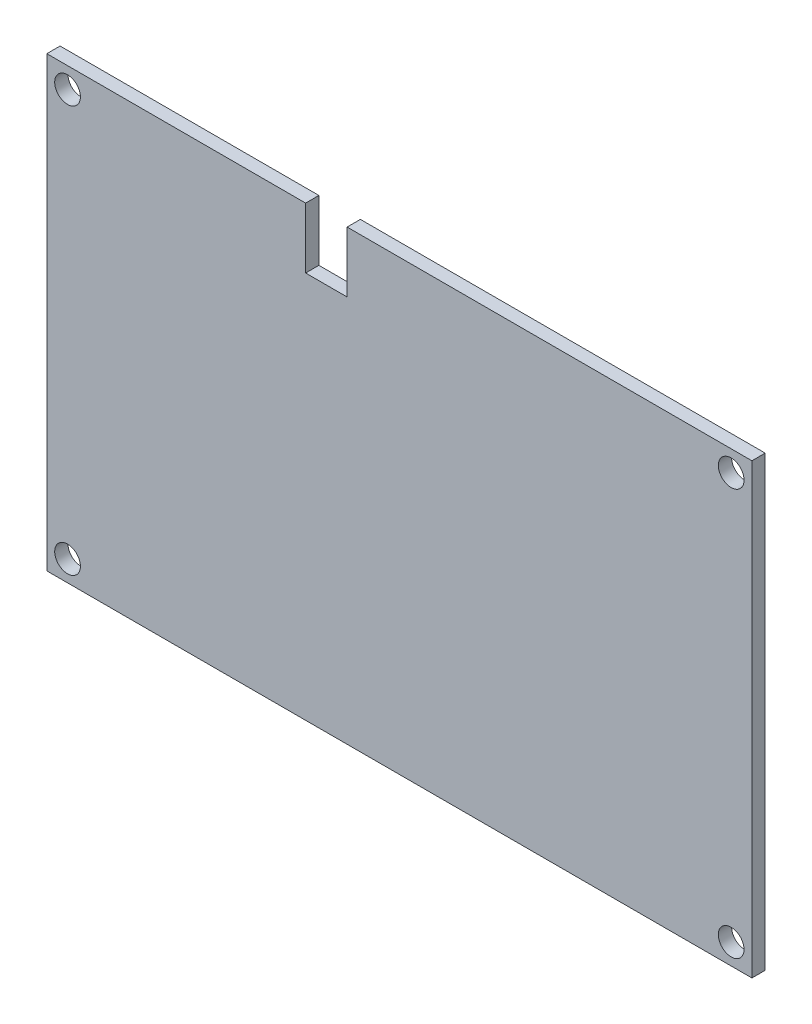
from build123d import *

# Parameters (mm, degrees)
SKETCH_1_R      = 1.55
EXTRUDE_1_DEPTH = 1.6


with BuildPart() as part:
    # Эскиз1 → Бобышка-Вытянуть1 (new body)
    with BuildSketch(Plane.XY):
        Polygon((0, 54), (31.2, 54), (31.2, 46.7), (36.2, 46.7), (36.2, 54), (85, 54), (85, 0), (0, 0), align=None)
        with Locations((2.5, 51.5)):
            Circle(SKETCH_1_R, mode=Mode.SUBTRACT)
        with Locations((82.5, 51.5)):
            Circle(SKETCH_1_R, mode=Mode.SUBTRACT)
        with Locations((82.5, 2.5)):
            Circle(SKETCH_1_R, mode=Mode.SUBTRACT)
        with Locations((2.5, 2.5)):
            Circle(SKETCH_1_R, mode=Mode.SUBTRACT)
    extrude(amount=EXTRUDE_1_DEPTH)


solid = part.part
